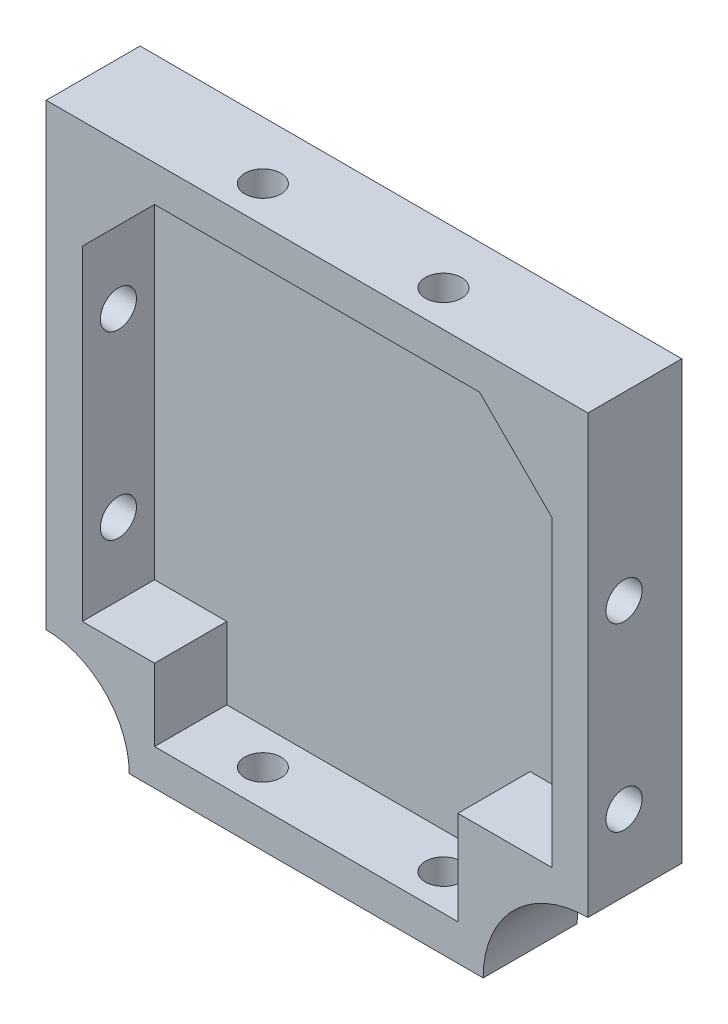
from build123d import *

# Parameters (mm, degrees)
BOSS_EXTRU_1_DEPTH        = 13
COQUE1_T                  = -5
COQUE1_THICKNESS_2_FACE_W = 65
COQUE1_THICKNESS_2_FACE_H = 65
COQUE1_THICKNESS_2_DEPTH  = 2
ENL_V_MAT_EXTRU_1_REACH   = 88.587
ESQUISSE2_R               = 2.5
ENL_V_MAT_EXTRU_2_REACH   = 95.396
ESQUISSE3_R               = 2.5
ESQUISSE4_W               = 18
ESQUISSE4_H               = 18
ESQUISSE4_W_2             = 15
ESQUISSE4_H_2             = 15
BOSS_EXTRU_2_DEPTH        = 10
ESQUISSE5_R               = 11.5
ESQUISSE5_R_2             = 14.5
ENL_V_MAT_EXTRU_3_DEPTH   = 13


with BuildPart() as part:
    # Esquisse1 → Boss.-Extru.1 (new body)
    with BuildSketch(Plane.XY):
        Polygon((44.118436308, 33.728448276), (54.118436308, 33.728448276), (54.118436308, 23.728448276), (54.118436308, -41.271551724), (-20.881563692, -41.271551724), (-20.881563692, 33.728448276), align=None)
    extrude(amount=BOSS_EXTRU_1_DEPTH)

    # Coque1
    coque1_openings = [part.faces().sort_by_distance(p)[0] for p in [
        (16.618436308, -3.771551724, 13),
    ]]
    offset(amount=COQUE1_T, openings=coque1_openings, kind=Kind.INTERSECTION)

    # Coque1 thickness 2 face (on inner face of the shell) → Coque1 thickness 2 (cut)
    with BuildSketch(Plane(origin=(16.618436308, -3.771551724, 5), x_dir=(-1, 0, 0), z_dir=(0, 0, -1))):
        Rectangle(COQUE1_THICKNESS_2_FACE_W, COQUE1_THICKNESS_2_FACE_H)
    extrude(amount=COQUE1_THICKNESS_2_DEPTH, mode=Mode.SUBTRACT)

    # Enlèv. mat.-Extru.1: up to this face of the body (flat: up to its plane)
    enl_v_mat_extru_1_end = Plane(part.part.faces().sort_by_distance((54.118436308, -3.771551724, 6.5))[0])
    # Esquisse2 → Enlèv. mat.-Extru.1 (cut, up to the picked face)
    with BuildSketch(Plane.ZY.offset(20.881563692), mode=Mode.PRIVATE) as enl_v_mat_extru_1_sk1:
        with Locations(Location((8, -16.271551724, 0), (0, 0, 270))):
            Circle(ESQUISSE2_R)
    enl_v_mat_extru_1_tool1 = split(extrude(enl_v_mat_extru_1_sk1.sketch, amount=-ENL_V_MAT_EXTRU_1_REACH, mode=Mode.PRIVATE), bisect_by=enl_v_mat_extru_1_end, keep=Keep.BOTH, mode=Mode.PRIVATE)
    # Esquisse2 → Enlèv. mat.-Extru.1 (cut, up to the picked face)
    with BuildSketch(Plane.ZY.offset(20.881563692), mode=Mode.PRIVATE) as enl_v_mat_extru_1_sk2:
        with Locations(Location((8, 8.728448276, 0), (0, 0, 270))):
            Circle(ESQUISSE2_R)
    enl_v_mat_extru_1_tool2 = split(extrude(enl_v_mat_extru_1_sk2.sketch, amount=-ENL_V_MAT_EXTRU_1_REACH, mode=Mode.PRIVATE), bisect_by=enl_v_mat_extru_1_end, keep=Keep.BOTH, mode=Mode.PRIVATE)
    add(enl_v_mat_extru_1_tool1.solids().sort_by(Axis((-20.881564, -16.271552, 8), (1, 0, 0)))[0], mode=Mode.SUBTRACT)
    add(enl_v_mat_extru_1_tool2.solids().sort_by(Axis((-20.881564, 8.728448, 8), (1, 0, 0)))[0], mode=Mode.SUBTRACT)

    # Enlèv. mat.-Extru.2: up to this face of the body (flat: up to its plane)
    enl_v_mat_extru_2_end = Plane(part.part.faces().sort_by_distance((16.618436308, 33.728448276, 6.5))[0])
    # Esquisse3 → Enlèv. mat.-Extru.2 (cut, up to the picked face)
    with BuildSketch(Plane.XZ.offset(41.271551724), mode=Mode.PRIVATE) as enl_v_mat_extru_2_sk1:
        with Locations(Location((4.118436308, 8, 0), (0, 0, 270))):
            Circle(ESQUISSE3_R)
    enl_v_mat_extru_2_tool1 = split(extrude(enl_v_mat_extru_2_sk1.sketch, amount=-ENL_V_MAT_EXTRU_2_REACH, mode=Mode.PRIVATE), bisect_by=enl_v_mat_extru_2_end, keep=Keep.BOTH, mode=Mode.PRIVATE)
    # Esquisse3 → Enlèv. mat.-Extru.2 (cut, up to the picked face)
    with BuildSketch(Plane.XZ.offset(41.271551724), mode=Mode.PRIVATE) as enl_v_mat_extru_2_sk2:
        with Locations(Location((29.118436308, 8, 0), (0, 0, 270))):
            Circle(ESQUISSE3_R)
    enl_v_mat_extru_2_tool2 = split(extrude(enl_v_mat_extru_2_sk2.sketch, amount=-ENL_V_MAT_EXTRU_2_REACH, mode=Mode.PRIVATE), bisect_by=enl_v_mat_extru_2_end, keep=Keep.BOTH, mode=Mode.PRIVATE)
    add(enl_v_mat_extru_2_tool1.solids().sort_by(Axis((4.118436, -41.271552, 8), (0, 1, 0)))[0], mode=Mode.SUBTRACT)
    add(enl_v_mat_extru_2_tool2.solids().sort_by(Axis((29.118436, -41.271552, 8), (0, 1, 0)))[0], mode=Mode.SUBTRACT)

    # Esquisse4 → Boss.-Extru.2 (add)
    with BuildSketch(Plane.XY.offset(3)):
        Polygon((-5.881563692, 28.728448276), (-15.881563692, 18.728448276), (-15.881563692, 28.728448276), align=None)
        Polygon((49.118436308, 28.728448276), (49.118436308, 18.728448276), (39.118436308, 28.728448276), align=None)
        with Locations((45.118436308, -32.271551724)):
            Rectangle(ESQUISSE4_W, ESQUISSE4_H)
        with Locations((-13.381563692, -33.771551724)):
            Rectangle(ESQUISSE4_W_2, ESQUISSE4_H_2)
    extrude(amount=BOSS_EXTRU_2_DEPTH)

    # Esquisse5 → Enlèv. mat.-Extru.3 (cut)
    with BuildSketch(Plane.XY.offset(13)):
        with Locations((-20.881563692, -41.271551724)):
            Circle(ESQUISSE5_R)
        with Locations((54.118436308, -41.271551724)):
            Circle(ESQUISSE5_R_2)
    extrude(amount=-ENL_V_MAT_EXTRU_3_DEPTH, mode=Mode.SUBTRACT)


solid = part.part
